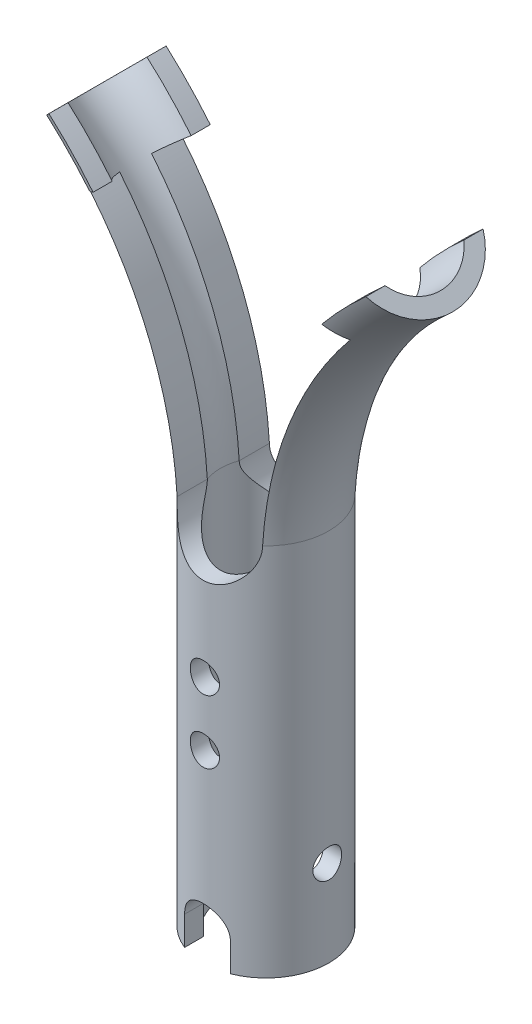
from build123d import *

# Parameters (mm, degrees)
SKETCH1_R               = 1.0922
SKETCH1_R_2             = 0.7922
EXTRUDE_THIN1_DEPTH     = 6.5
CUT_EXTRUDE1_DEPTH      = 12.867333696
CUT_EXTRUDE1_DEPTH_BACK = 12.867333696
SKETCH5_R               = 0.7422
CUT_EXTRUDE5_DEPTH      = 10
CUT_EXTRUDE5_DEPTH_BACK = 10
SKETCH10_R              = 0.254
CUT_EXTRUDE4_DEPTH      = 10
CUT_EXTRUDE4_DEPTH_BACK = 10
SKETCH9_R               = 0.25


with BuildPart() as part:
    # Sketch1 → Extrude-Thin1 (new body)
    with BuildSketch(Plane(origin=(0, 0, 0), x_dir=(1, 0, 0), z_dir=(0, 1, 0))):
        Circle(SKETCH1_R)
        Circle(SKETCH1_R_2, mode=Mode.SUBTRACT)
    extrude(amount=EXTRUDE_THIN1_DEPTH)

    # Sweep2: sweep along a path in Sketch4_2
    with BuildLine(Plane.XY) as sweep2_path:
        ThreePointArc((-1.0922, 6.5), (-1.734234713, 8.899597356), (-3.24479024, 10.87152485))
    # Sketch12 → Sweep2 (sweep)
    with BuildSketch(Plane(origin=(0, 6.5, 0), x_dir=(1, 0, 0), z_dir=(0, 1, 0))):
        with BuildLine():
            Line((-0.396875, -1.017541682), (-0.396875, -0.685617294))
            ThreePointArc((-0.396875, -0.685617294), (-0.7922, 0), (-0.396875, 0.685617294))
            Line((-0.396875, 0.685617294), (-0.396875, 1.017541682))
            ThreePointArc((-0.396875, 1.017541682), (-1.0922, 0), (-0.396875, -1.017541682))
        make_face()
    sweep2 = sweep(path=sweep2_path.line)

    # Cut-Sweep1: sweep along a path in Sketch13
    with BuildLine(Plane.XY) as cut_sweep1_path:
        ThreePointArc((-1.0922, 6.5), (-1.531167448, 8.442831006), (-2.54839741, 10.155293544))
    # Sketch14 → Cut-Sweep1 (sweep, cut)
    with BuildSketch(Plane(origin=(0, 6.5, 0), x_dir=(1, 0, 0), z_dir=(0, 1, 0))):
        with BuildLine():
            Line((-0.396875, -1.017541682), (-0.396875, -0.685617294))
            ThreePointArc((-0.396875, -0.685617294), (-0.605077108, -0.511334072), (-0.7422, -0.276983754))
            Line((-0.7422, -0.276983754), (-0.7422, -0.801273986))
            ThreePointArc((-0.7422, -0.801273986), (-0.579711905, -0.925653794), (-0.396875, -1.017541682))
        make_face()
        with BuildLine():
            Line((-0.396875, 0.685617294), (-0.396875, 1.017541682))
            ThreePointArc((-0.396875, 1.017541682), (-0.579711905, 0.925653794), (-0.7422, 0.801273986))
            Line((-0.7422, 0.801273986), (-0.7422, 0.276983754))
            ThreePointArc((-0.7422, 0.276983754), (-0.605077108, 0.511334072), (-0.396875, 0.685617294))
        make_face()
    cut_sweep1 = sweep(path=cut_sweep1_path.line, mode=Mode.SUBTRACT)

    # Mirror1: Sweep2, Cut-Sweep1 across plane
    add(sweep2.mirror(Plane(origin=(0, 0, 0), x_dir=(0, 0, 1), z_dir=(1, 0, 0))))
    add(cut_sweep1.mirror(Plane(origin=(0, 0, 0), x_dir=(0, 0, 1), z_dir=(1, 0, 0))), mode=Mode.SUBTRACT)

    # Sketch5 → Cut-Extrude1 (cut, two sides: drawn at the far end of the back side and taken through both)
    with BuildSketch(Plane.XY.offset(-CUT_EXTRUDE1_DEPTH_BACK)):
        with Locations((0, 6.5)):
            Circle(SKETCH5_R)
    extrude(amount=CUT_EXTRUDE1_DEPTH + CUT_EXTRUDE1_DEPTH_BACK, mode=Mode.SUBTRACT)

    # Sketch10 → Cut-Extrude5 (cut, two sides: drawn at the far end of the back side and taken through both)
    with BuildSketch(Plane.XY.offset(-CUT_EXTRUDE5_DEPTH_BACK)):
        with Locations((0.001350263, 4.3)):
            Circle(SKETCH10_R)
        with Locations((0.001426468, 3.200000003)):
            Circle(SKETCH10_R)
        with BuildLine():
            Line((0.398301468, 0.5), (0.398301468, 0))
            Line((0.398301468, 0), (-0.395448532, 0))
            Line((-0.395448532, 0), (-0.395448532, 0.5))
            ThreePointArc((-0.395448532, 0.5), (0.001426468, 0.896875), (0.398301468, 0.5))
        make_face()
    extrude(amount=CUT_EXTRUDE5_DEPTH + CUT_EXTRUDE5_DEPTH_BACK, mode=Mode.SUBTRACT)

    # Sketch9 → Cut-Extrude4 (cut, two sides: drawn at the far end of the back side and taken through both)
    with BuildSketch(Plane(origin=(0, 0, 0), x_dir=(0, 0, -1), z_dir=(1, 0, 0)).offset(-CUT_EXTRUDE4_DEPTH_BACK)):
        with Locations((0, 1.5)):
            Circle(SKETCH9_R)
    extrude(amount=CUT_EXTRUDE4_DEPTH + CUT_EXTRUDE4_DEPTH_BACK, mode=Mode.SUBTRACT)


solid = part.part
